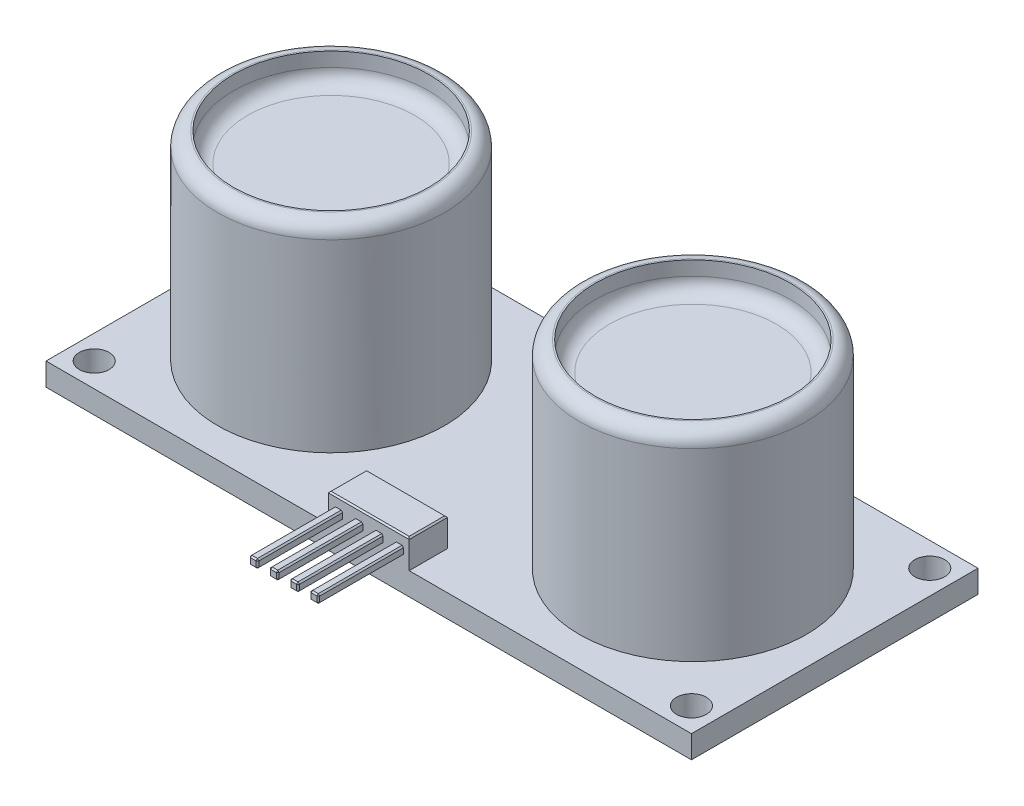
from build123d import *

# Parameters (mm, degrees)
SKETCH1_W            = 45.5
SKETCH1_H            = 20.2
BOSS_EXTRUDE1_DEPTH  = 1.6
SKETCH2_R            = 8
BOSS_EXTRUDE2_DEPTH  = 14
SKETCH3_R            = 6.893962295
CUT_EXTRUDE1_DEPTH   = 2
FILLET1_R            = 1
FILLET2_R            = 1
FILLET1_OF_MIRROR1_R = 1
FILLET2_OF_MIRROR1_R = 1
BOSS_EXTRUDE3_DEPTH  = 2
SKETCH5_W            = 0.6
SKETCH5_H            = 0.6
BOSS_EXTRUDE4_DEPTH  = 6
CHAMFER1_SIZE        = 0.1
CHAMFER2_SIZE        = 0.1
CUT_EXTRUDE2_REACH   = 53.714
SKETCH6_R            = 1.05


with BuildPart() as part:
    # Sketch1 → Boss-Extrude1 (new body)
    with BuildSketch(Plane(origin=(0, 0, 0), x_dir=(1, 0, 0), z_dir=(0, 1, 0))):
        with Locations((22.75, 10.1)):
            Rectangle(SKETCH1_W, SKETCH1_H)
    extrude(amount=BOSS_EXTRUDE1_DEPTH)

    # Sketch2 → Boss-Extrude2 (add)
    with BuildSketch(Plane(origin=(0, 1.6, 0), x_dir=(1, 0, 0), z_dir=(0, 1, 0))):
        with Locations((10, 10.1)):
            Circle(SKETCH2_R)
    boss_extrude2 = extrude(amount=BOSS_EXTRUDE2_DEPTH)

    # Sketch3 → Cut-Extrude1 (cut)
    with BuildSketch(Plane(origin=(0, 15.6, 0), x_dir=(1, 0, 0), z_dir=(0, 1, 0))):
        with Locations((10, 10.1)):
            Circle(SKETCH3_R)
    cut_extrude1 = extrude(amount=-CUT_EXTRUDE1_DEPTH, mode=Mode.SUBTRACT)

    # Fillet1
    fillet1_edges = [part.edges().sort_by_distance(p)[0] for p in [
        (2, 15.6, -10.1),
    ]]
    fillet(fillet1_edges, radius=FILLET1_R)

    # Fillet2
    fillet2_edges = [part.edges().sort_by_distance(p)[0] for p in [
        (3.106037705, 13.6, -10.1),
    ]]
    fillet(fillet2_edges, radius=FILLET2_R)

    # Mirror1: Boss-Extrude2, Cut-Extrude1 across plane
    add(boss_extrude2.mirror(Plane(origin=(22.75, 0, 0), x_dir=(0, 0, 1), z_dir=(1, 0, 0))))
    add(cut_extrude1.mirror(Plane(origin=(22.75, 0, 0), x_dir=(0, 0, 1), z_dir=(1, 0, 0))), mode=Mode.SUBTRACT)

    # Fillet1 of Mirror1
    fillet1_of_mirror1_edges = [part.edges().sort_by_distance(p)[0] for p in [
        (43.5, 15.6, -10.1),
    ]]
    fillet(fillet1_of_mirror1_edges, radius=FILLET1_OF_MIRROR1_R)

    # Fillet2 of Mirror1
    fillet2_of_mirror1_edges = [part.edges().sort_by_distance(p)[0] for p in [
        (42.393962295, 13.6, -10.1),
    ]]
    fillet(fillet2_of_mirror1_edges, radius=FILLET2_OF_MIRROR1_R)

    # Sketch4 → Boss-Extrude3 (add)
    with BuildSketch(Plane(origin=(0, 1.6, 0), x_dir=(1, 0, 0), z_dir=(0, 1, 0))):
        Polygon((22.75, 0), (19.9, 0), (19.9, 2.7), (25.6, 2.7), (25.6, 0), align=None)
    extrude(amount=BOSS_EXTRUDE3_DEPTH)

    # Sketch5 → Boss-Extrude4 (add)
    with BuildSketch(Plane.XY):
        with Locations((20.606248373, 2.6)):
            Rectangle(SKETCH5_W, SKETCH5_H)
        with Locations((22.036248373, 2.6)):
            Rectangle(SKETCH5_W, SKETCH5_H)
        with Locations((23.466248373, 2.6)):
            Rectangle(SKETCH5_W, SKETCH5_H)
        with Locations((24.896248373, 2.6)):
            Rectangle(SKETCH5_W, SKETCH5_H)
    extrude(amount=BOSS_EXTRUDE4_DEPTH)

    # Chamfer1
    chamfer1_edges = [part.edges().sort_by_distance(p)[0] for p in [
        (25.196248373, 2.6, 6),
        (25.196248373, 2.3, 3),
        (24.896248373, 2.3, 6),
        (24.596248373, 2.3, 3),
        (24.596248373, 2.6, 6),
        (25.196248373, 2.9, 3),
        (24.896248373, 2.9, 6),
        (24.596248373, 2.9, 3),
        (23.766248373, 2.6, 6),
        (23.766248373, 2.3, 3),
        (23.466248373, 2.3, 6),
        (23.166248373, 2.3, 3),
        (23.166248373, 2.6, 6),
        (23.166248373, 2.9, 3),
        (23.466248373, 2.9, 6),
        (23.766248373, 2.9, 3),
        (22.336248373, 2.6, 6),
        (22.336248373, 2.3, 3),
        (22.036248373, 2.3, 6),
        (21.736248373, 2.3, 3),
        (21.736248373, 2.6, 6),
        (22.336248373, 2.9, 3),
        (22.036248373, 2.9, 6),
        (21.736248373, 2.9, 3),
        (20.606248373, 2.3, 6),
        (20.306248373, 2.3, 3),
        (20.306248373, 2.6, 6),
        (20.306248373, 2.9, 3),
        (20.606248373, 2.9, 6),
        (20.906248373, 2.3, 3),
        (20.906248373, 2.6, 6),
        (20.906248373, 2.9, 3),
    ]]
    chamfer(chamfer1_edges, length=CHAMFER1_SIZE)

    # Chamfer2
    chamfer2_edges = [part.edges().sort_by_distance(p)[0] for p in [
        (19.9, 3.6, -1.35),
        (22.75, 3.6, -2.7),
        (25.6, 3.6, -1.35),
        (22.75, 3.6, 0),
    ]]
    chamfer(chamfer2_edges, length=CHAMFER2_SIZE)

    # Sketch6 → Cut-Extrude2 (cut, up to next)
    with BuildSketch(Plane(origin=(0, 1.6, 0), x_dir=(1, 0, 0), z_dir=(0, 1, 0)), mode=Mode.PRIVATE) as cut_extrude2_sk1:
        with Locations((1.7, 18.5)):
            Circle(SKETCH6_R)
    cut_extrude2_tool1 = extrude(cut_extrude2_sk1.sketch, amount=-CUT_EXTRUDE2_REACH, mode=Mode.PRIVATE) & part.part
    # Sketch6 → Cut-Extrude2 (cut, up to next)
    with BuildSketch(Plane(origin=(0, 1.6, 0), x_dir=(1, 0, 0), z_dir=(0, 1, 0)), mode=Mode.PRIVATE) as cut_extrude2_sk2:
        with Locations((1.7, 1.7)):
            Circle(SKETCH6_R)
    cut_extrude2_tool2 = extrude(cut_extrude2_sk2.sketch, amount=-CUT_EXTRUDE2_REACH, mode=Mode.PRIVATE) & part.part
    # Sketch6 → Cut-Extrude2 (cut, up to next)
    with BuildSketch(Plane(origin=(0, 1.6, 0), x_dir=(1, 0, 0), z_dir=(0, 1, 0)), mode=Mode.PRIVATE) as cut_extrude2_sk3:
        with Locations((43.8, 1.7)):
            Circle(SKETCH6_R)
    cut_extrude2_tool3 = extrude(cut_extrude2_sk3.sketch, amount=-CUT_EXTRUDE2_REACH, mode=Mode.PRIVATE) & part.part
    # Sketch6 → Cut-Extrude2 (cut, up to next)
    with BuildSketch(Plane(origin=(0, 1.6, 0), x_dir=(1, 0, 0), z_dir=(0, 1, 0)), mode=Mode.PRIVATE) as cut_extrude2_sk4:
        with Locations((43.8, 18.5)):
            Circle(SKETCH6_R)
    cut_extrude2_tool4 = extrude(cut_extrude2_sk4.sketch, amount=-CUT_EXTRUDE2_REACH, mode=Mode.PRIVATE) & part.part
    add(cut_extrude2_tool1.solids().sort_by_distance((1.7, 1.6, -18.5))[0], mode=Mode.SUBTRACT)
    add(cut_extrude2_tool2.solids().sort_by_distance((1.7, 1.6, -1.7))[0], mode=Mode.SUBTRACT)
    add(cut_extrude2_tool3.solids().sort_by_distance((43.8, 1.6, -1.7))[0], mode=Mode.SUBTRACT)
    add(cut_extrude2_tool4.solids().sort_by_distance((43.8, 1.6, -18.5))[0], mode=Mode.SUBTRACT)


solid = part.part
